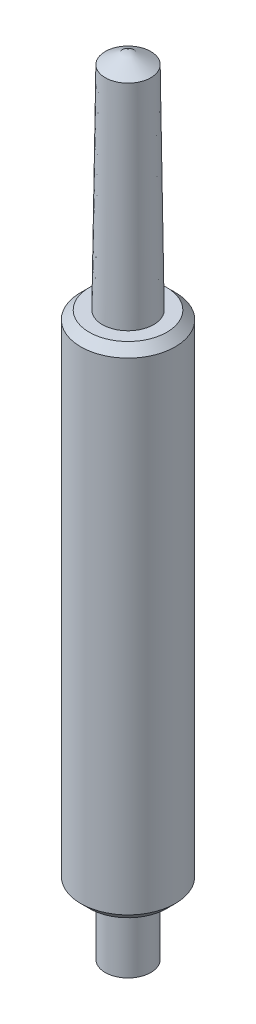
from build123d import *


with BuildPart() as part:
    # Sketch1 → Revolve1 (revolve)
    with BuildSketch(Plane(origin=(0, 0, 0), x_dir=(-1, 0, 0), z_dir=(0, 0, -1))):
        Polygon((-0.135, 0.07339164), (0, 0), (0, 4.75), (-0.135, 4.67), (-0.152, 3.41), (-0.23, 3.41), (-0.28, 3.36), (-0.28, 0.5), (-0.23, 0.45), (-0.135, 0.45), align=None)
    revolve(axis=Axis((0, -1000, 0), (0, 1, 0)))


solid = part.part
